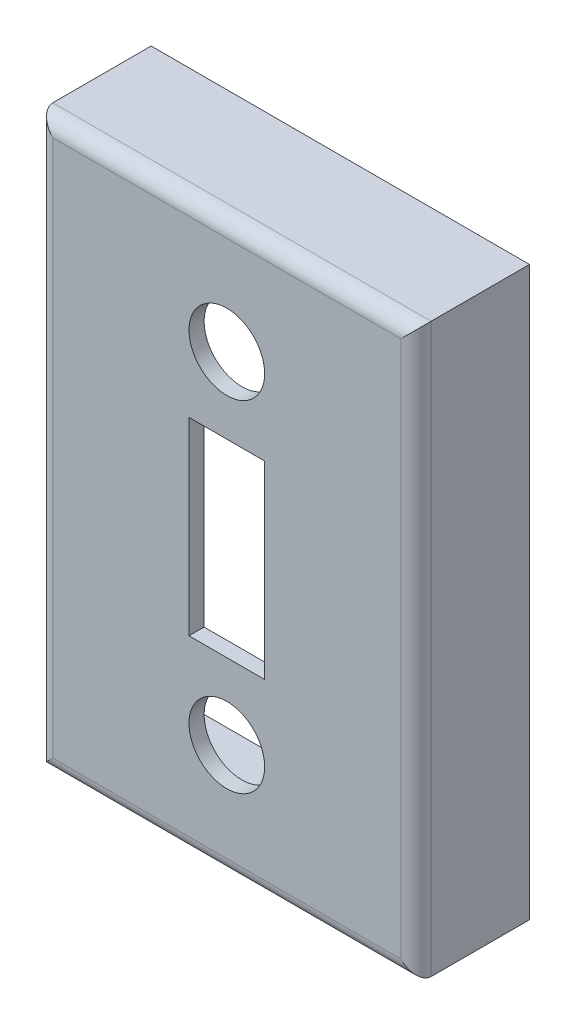
from build123d import *

# Parameters (mm, degrees)
SKETCH1_W           = 50
SKETCH1_H           = 75
BOSS_EXTRUDE1_DEPTH = 15
SHELL3_T            = -2
FILLET1_R           = 2
SKETCH2_R           = 5
SKETCH2_W           = 10
SKETCH2_H           = 25
CUT_EXTRUDE1_DEPTH  = 16


with BuildPart() as part:
    # Sketch1 → Boss-Extrude1 (new body)
    with BuildSketch(Plane.XY):
        with Locations((25, 37.5)):
            Rectangle(SKETCH1_W, SKETCH1_H)
    extrude(amount=BOSS_EXTRUDE1_DEPTH)

    # Shell3
    shell3_openings = [part.faces().sort_by_distance(p)[0] for p in [
        (25, 37.5, 0),
    ]]
    offset(amount=SHELL3_T, openings=shell3_openings, kind=Kind.INTERSECTION)

    # Fillet1
    fillet1_edges = [part.edges().sort_by_distance(p)[0] for p in [
        (50, 37.5, 15),
        (25, 75, 15),
        (0, 37.5, 15),
        (25, 0, 15),
    ]]
    fillet(fillet1_edges, radius=FILLET1_R)

    # Sketch2 → Cut-Extrude1 (cut, through all)
    with BuildSketch(Plane.XY.offset(15)):
        with Locations((25, 60)):
            Circle(SKETCH2_R)
        with Locations((25, 15)):
            Circle(SKETCH2_R)
        with Locations((25, 37.5)):
            Rectangle(SKETCH2_W, SKETCH2_H)
    extrude(amount=-CUT_EXTRUDE1_DEPTH, mode=Mode.SUBTRACT)


solid = part.part
